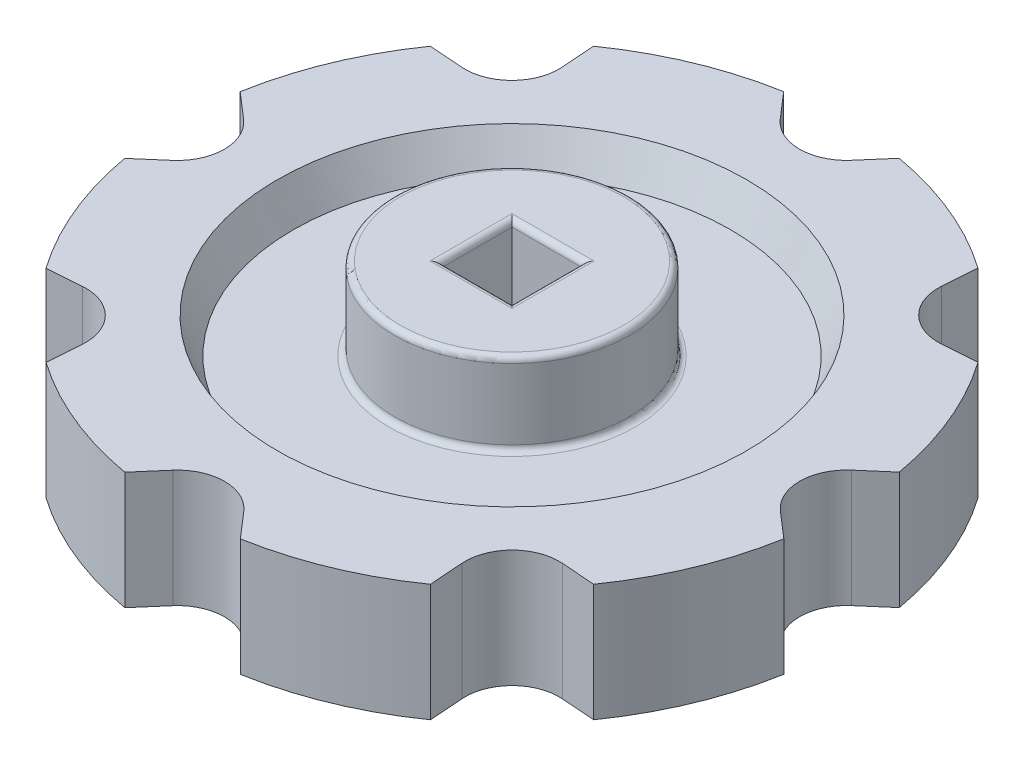
from build123d import *

# Parameters (mm, degrees)
SKETCH_1_W          = 10
SKETCH_1_H          = 7
SKETCH_1_H_2        = 1
FILLET_3_R          = 0.5
FILLET_4_R          = 0.5
CUT_EXTRUDE_1_DEPTH = 10
CUT_EXTRUDE_2_REACH = 14
SKETCH_5_W          = 6
SKETCH_5_H          = 6
FILLET_5_R          = 0.5
FILLET_6_R          = 0.5


with BuildPart() as part:
    # Эскиз1 → Повернуть1 (revolve)
    with BuildSketch(Plane.XY):
        Polygon((20, 4), (20, 2), (20, 0), (20, -3), (28.5, -3), (28.5, 7), (20, 7), align=None)
        Polygon((20, 0), (20, 2), (20, 4), (18.625227292, 4), (10, 4), (0, 4), (0, 0), (10, 0), (18.625227292, 0), align=None)
        with Locations((5, 7.5)):
            Rectangle(SKETCH_1_W, SKETCH_1_H)
        with Locations((5, -0.5)):
            Rectangle(SKETCH_1_W, SKETCH_1_H_2)
        Polygon((18.625227292, 4), (20, 4), (20, 7), align=None)
        Polygon((20, -3), (20, 0), (18.625227292, 0), align=None)
    revolve(axis=Axis((0, 0, 0), (0, 1, 0)))

    # Скругление3
    fillet_3_edges = [part.edges().sort_by_distance(p)[0] for p in [
        (-10, 4, 0),
    ]]
    fillet(fillet_3_edges, radius=FILLET_3_R)

    # Скругление4
    fillet_4_edges = [part.edges().sort_by_distance(p)[0] for p in [
        (-10, 0, 0),
    ]]
    fillet(fillet_4_edges, radius=FILLET_4_R)

    # Эскиз4 → Вырез-Вытянуть1 (cut)
    with BuildSketch(Plane(origin=(0, 7, 0), x_dir=(1, 0, 0), z_dir=(0, 1, 0))):
        with BuildLine():
            Line((-3.032652989, 25.883771919), (-8.753058696, 32.499672333))
            Line((-8.753058696, 32.499672333), (8.739316139, 32.499672333))
            Line((8.739316139, 32.499672333), (3.018910432, 25.883771919))
            ThreePointArc((3.018910432, 25.883771919), (-0.006871279, 24.499999172), (-3.032652989, 25.883771919))
        make_face()
        with BuildLine():
            Line((16.791391533, 29.170085853), (29.160368398, 16.801108988))
            Line((29.160368398, 16.801108988), (20.437282685, 16.167898608))
            ThreePointArc((20.437282685, 16.167898608), (17.319256826, 17.328974281), (16.158181153, 20.44700014))
            Line((16.158181153, 20.44700014), (16.791391533, 29.170085853))
        make_face()
        with BuildLine():
            Line((32.499672333, 8.753058696), (32.499672333, -8.739316139))
            Line((32.499672333, -8.739316139), (25.883771919, -3.018910432))
            ThreePointArc((25.883771919, -3.018910432), (24.499999172, 0.006871279), (25.883771919, 3.032652989))
            Line((25.883771919, 3.032652989), (32.499672333, 8.753058696))
        make_face()
        with BuildLine():
            Line((29.170085853, -16.791391533), (16.801108988, -29.160368398))
            Line((16.801108988, -29.160368398), (16.167898608, -20.437282685))
            ThreePointArc((16.167898608, -20.437282685), (17.328974281, -17.319256826), (20.44700014, -16.158181153))
            Line((20.44700014, -16.158181153), (29.170085853, -16.791391533))
        make_face()
        with BuildLine():
            Line((8.753058696, -32.499672333), (-8.739316139, -32.499672333))
            Line((-8.739316139, -32.499672333), (-3.018910432, -25.883771919))
            ThreePointArc((-3.018910432, -25.883771919), (0.006871279, -24.499999172), (3.032652989, -25.883771919))
            Line((3.032652989, -25.883771919), (8.753058696, -32.499672333))
        make_face()
        with BuildLine():
            Line((-16.791391533, -29.170085853), (-29.160368398, -16.801108988))
            Line((-29.160368398, -16.801108988), (-20.437282685, -16.167898608))
            ThreePointArc((-20.437282685, -16.167898608), (-17.319256826, -17.328974281), (-16.158181153, -20.44700014))
            Line((-16.158181153, -20.44700014), (-16.791391533, -29.170085853))
        make_face()
        with BuildLine():
            Line((-32.499672333, -8.753058696), (-32.499672333, 8.739316139))
            Line((-32.499672333, 8.739316139), (-25.883771919, 3.018910432))
            ThreePointArc((-25.883771919, 3.018910432), (-24.499999172, -0.006871279), (-25.883771919, -3.032652989))
            Line((-25.883771919, -3.032652989), (-32.499672333, -8.753058696))
        make_face()
        with BuildLine():
            Line((-29.170085853, 16.791391533), (-16.801108988, 29.160368398))
            Line((-16.801108988, 29.160368398), (-16.167898608, 20.437282685))
            ThreePointArc((-16.167898608, 20.437282685), (-17.328974281, 17.319256826), (-20.44700014, 16.158181153))
            Line((-20.44700014, 16.158181153), (-29.170085853, 16.791391533))
        make_face()
    extrude(amount=-CUT_EXTRUDE_1_DEPTH, mode=Mode.SUBTRACT)

    # Эскиз5 → Вырез-Вытянуть2 (cut, up to next)
    with BuildSketch(Plane.XZ.offset(1), mode=Mode.PRIVATE) as cut_extrude_2_sk1:
        Rectangle(SKETCH_5_W, SKETCH_5_H)
    cut_extrude_2_tool1 = extrude(cut_extrude_2_sk1.sketch, amount=-CUT_EXTRUDE_2_REACH, mode=Mode.PRIVATE) & part.part
    add(cut_extrude_2_tool1.solids().sort_by_distance((0, -1, 0))[0], mode=Mode.SUBTRACT)

    # Скругление5
    fillet_5_edges = [part.edges().sort_by_distance(p)[0] for p in [
        (3, -1, 0),
        (0, -1, 3),
        (-3, -1, 0),
        (0, -1, -3),
        (0, 11, 3),
        (3, 11, 0),
        (0, 11, -3),
        (-3, 11, 0),
    ]]
    fillet(fillet_5_edges, radius=FILLET_5_R)

    # Скругление6
    fillet_6_edges = [part.edges().sort_by_distance(p)[0] for p in [
        (-10, 11, 0),
    ]]
    fillet(fillet_6_edges, radius=FILLET_6_R)


solid = part.part
